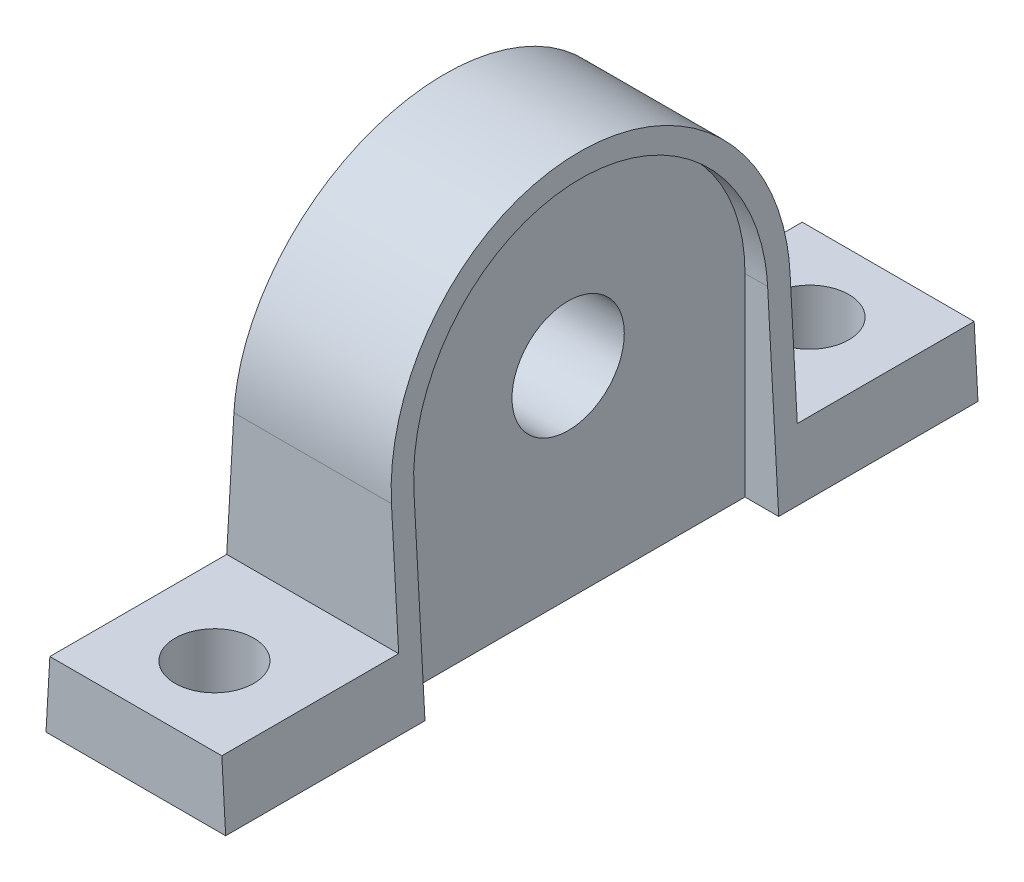
from build123d import *

# Parameters (mm, degrees)
EXTRUDE_1_DEPTH     = 67
SKETCH_2_R          = 5
CUT_EXTRUDE_1_DEPTH = 15
CUT_EXTRUDE_2_DEPTH = 3
SKETCH_4_R          = 7
SKETCH_4_R_2        = 5
EXTRUDE_2_DEPTH     = 5
SKETCH_5_R          = 3.5
CUT_EXTRUDE_4_DEPTH = 10


with BuildPart() as part:
    # 草图1 → 凸台-拉伸1 (new body)
    with BuildSketch(Plane.XY):
        Polygon((8, 0), (-8, 0), (-6, 35), (6, 35), align=None)
    extrude(amount=EXTRUDE_1_DEPTH)

    # 草图2 → 切除-拉伸1 (cut, symmetric)
    with BuildSketch(Plane(origin=(0, 0, 0), x_dir=(0, 0, -1), z_dir=(1, 0, 0))):
        with BuildLine():
            Line((-67, 35), (-67, 6))
            Line((-67, 6), (-51.25, 6))
            Line((-51.25, 6), (-51.25, 17.25))
            ThreePointArc((-51.25, 17.25), (-46.051145366, 29.801145366), (-33.5, 35))
            Line((-33.5, 35), (-67, 35))
        make_face()
        with BuildLine():
            Line((0, 35), (-33.5, 35))
            ThreePointArc((-33.5, 35), (-20.948854634, 29.801145366), (-15.75, 17.25))
            Line((-15.75, 17.25), (-15.75, 6))
            Line((-15.75, 6), (0, 6))
            Line((0, 6), (0, 35))
        make_face()
        with Locations((-33.5, 18)):
            Circle(SKETCH_2_R)
    extrude(amount=CUT_EXTRUDE_1_DEPTH, both=True, mode=Mode.SUBTRACT)

    # 草图3 → 切除-拉伸2 (cut)
    with BuildSketch(Plane(origin=(8, 0, 0), x_dir=(0, 0, -1), z_dir=(1, 0, 0))):
        with BuildLine():
            Line((-49.25, 6), (-49.25, 0))
            Line((-49.25, 0), (-17.75, 0))
            Line((-17.75, 0), (-17.75, 6))
            Line((-17.75, 6), (-17.75, 17.25))
            ThreePointArc((-17.75, 17.25), (-33.5, 33), (-49.25, 17.25))
            Line((-49.25, 17.25), (-49.25, 6))
        make_face()
    cut_extrude_2 = extrude(amount=-CUT_EXTRUDE_2_DEPTH, mode=Mode.SUBTRACT)

    # 镜向1: 切除-拉伸2 across plane
    add(cut_extrude_2.mirror(Plane(origin=(0, 0, 0), x_dir=(0, 0, 1), z_dir=(1, 0, 0))), mode=Mode.SUBTRACT)

    # 草图4 → 凸台-拉伸2 (add)
    with BuildSketch(Plane(origin=(-10, 0, 0), x_dir=(0, 0, -1), z_dir=(1, 0, 0))):
        with Locations((-33.5, 18)):
            Circle(SKETCH_4_R)
        with Locations((-33.5, 18)):
            Circle(SKETCH_4_R_2, mode=Mode.SUBTRACT)
    extrude(amount=EXTRUDE_2_DEPTH)

    # 草图5 → 切除-拉伸4 (cut)
    with BuildSketch(Plane.XZ):
        with Locations((0, 60)):
            Circle(SKETCH_5_R)
        with Locations((0, 7)):
            Circle(SKETCH_5_R)
    extrude(amount=-CUT_EXTRUDE_4_DEPTH, mode=Mode.SUBTRACT)


solid = part.part
